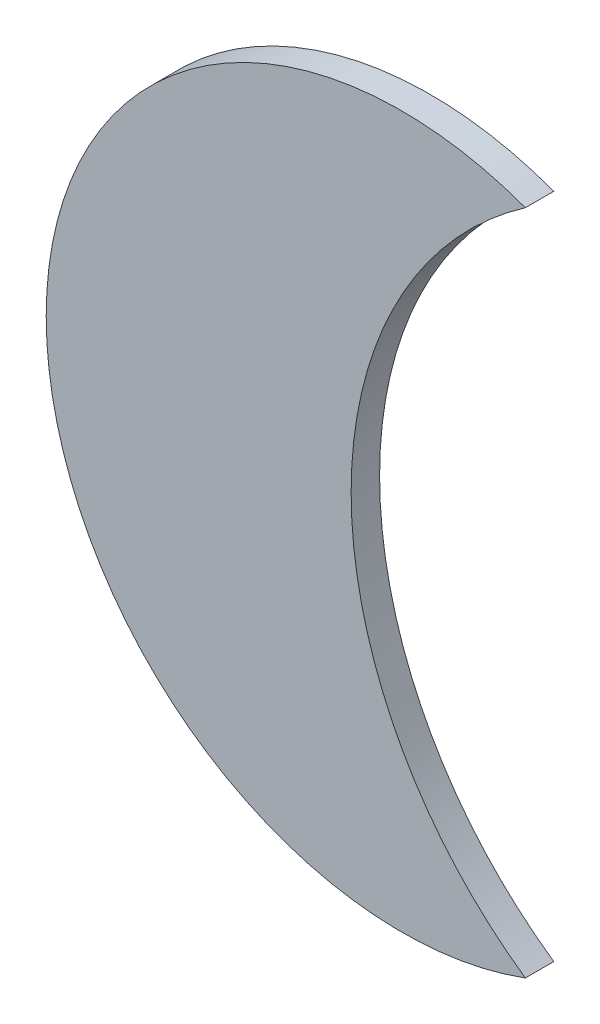
from build123d import *

# Parameters (mm, degrees)
EXTRUDE_1_DEPTH = 20


with BuildPart() as part:
    # 草图1 → 凸台-拉伸1 (new body)
    with BuildSketch(Plane.XY):
        with BuildLine():
            ThreePointArc((86.797147672, 234.448832704), (-250, 0), (86.797147672, -234.448832704))
            ThreePointArc((86.797147672, -234.448832704), (-35.659633417, 0), (86.797147672, 234.448832704))
        make_face()
    extrude(amount=EXTRUDE_1_DEPTH)


solid = part.part
